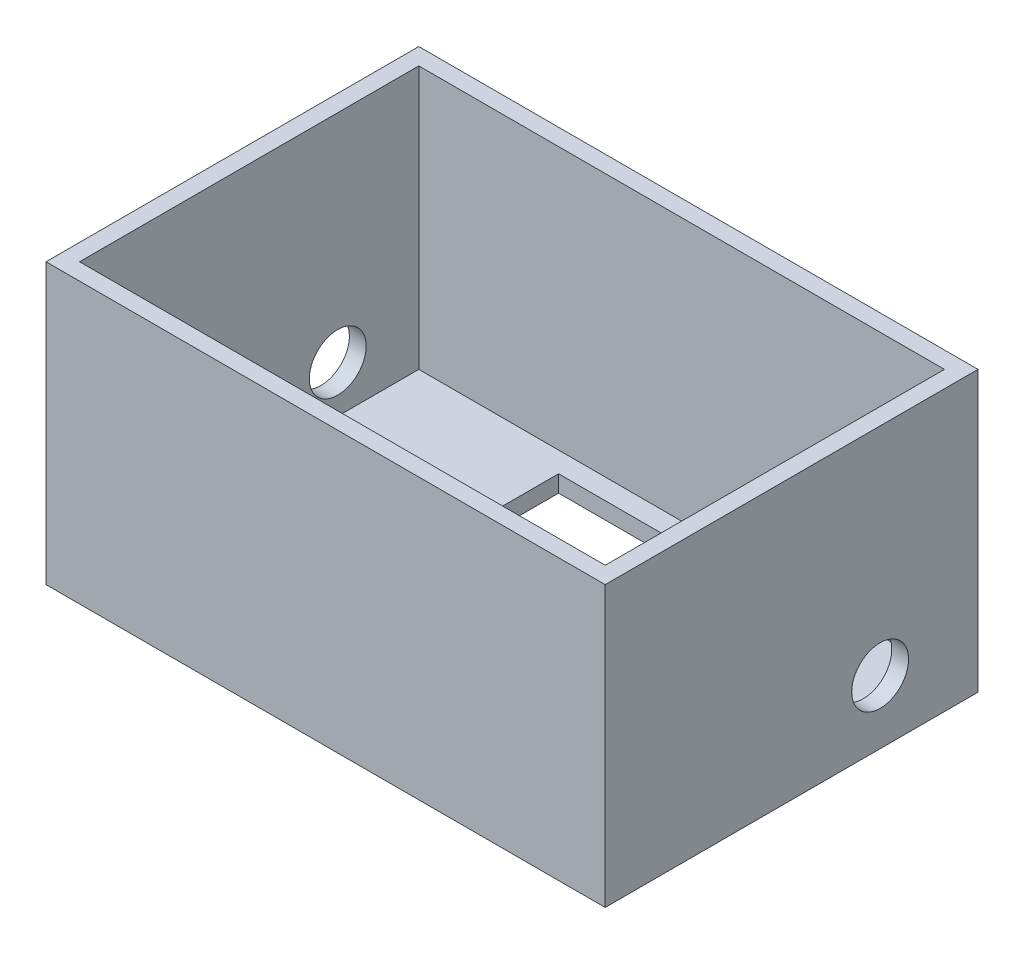
from build123d import *

# Parameters (mm, degrees)
SKETCH2_W             = 60
SKETCH2_H             = 40
BOSS_EXTRUDE1_DEPTH   = 30
SHELL2_T              = -1.8
SKETCH2_6_W           = 22
SKETCH2_6_H           = 13
CUT_EXTRUDE4_DEPTH    = 30
F_6_0MM_DOWEL_HOLE1_D = 6.1


with BuildPart() as part:
    # Sketch2 → Boss-Extrude1 (new body)
    with BuildSketch(Plane(origin=(0, 0, 0), x_dir=(1, 0, 0), z_dir=(0, 1, 0))):
        with Locations((30, 20)):
            Rectangle(SKETCH2_W, SKETCH2_H)
    extrude(amount=BOSS_EXTRUDE1_DEPTH)

    # Shell2
    shell2_openings = [part.faces().sort_by_distance(p)[0] for p in [
        (30, 30, -20),
    ]]
    offset(amount=SHELL2_T, openings=shell2_openings, kind=Kind.INTERSECTION)

    # Sketch2_6 → Cut-Extrude4 (cut)
    with BuildSketch(Plane(origin=(0, 0, 0), x_dir=(1, 0, 0), z_dir=(0, 1, 0))):
        with Locations((30, 29.5)):
            Rectangle(SKETCH2_6_W, SKETCH2_6_H)
    extrude(amount=CUT_EXTRUDE4_DEPTH, mode=Mode.SUBTRACT)

    # Ø6.0mm Dowel Hole1 (through all)
    with Locations(Plane.ZY):
        with Locations((-29.5, 6.8)):
            Hole(F_6_0MM_DOWEL_HOLE1_D / 2)


solid = part.part
